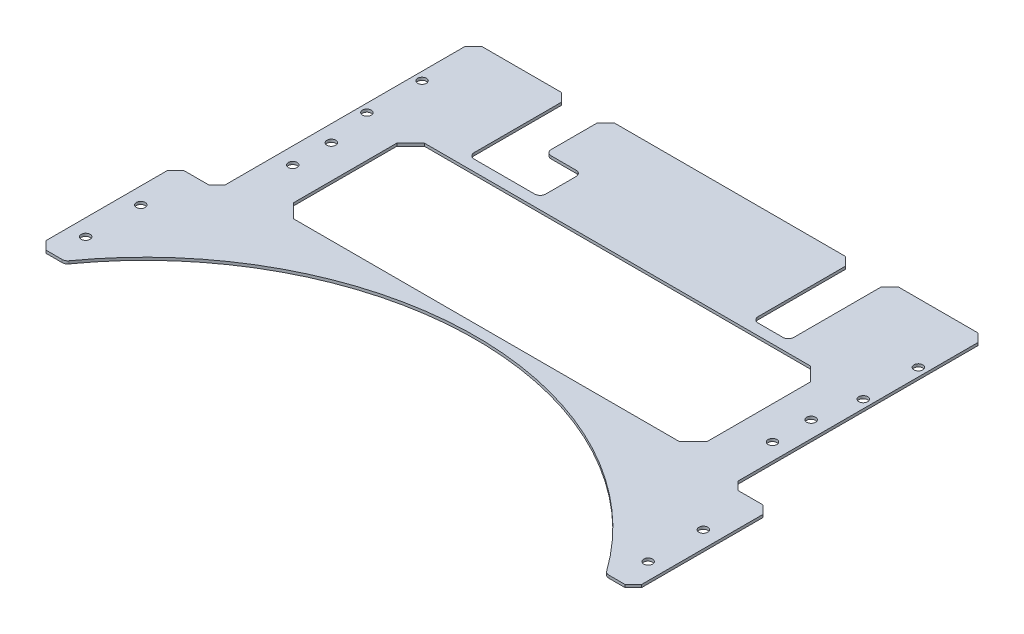
from build123d import *

# Parameters (mm, degrees)
SKETCH_1_W               = 186
SKETCH_1_H               = 110
EXTRUDE_1_DEPTH          = 1
SKETCH_2_R               = 1.6
CUT_EXTRUDE_1_DEPTH      = 2
EXTRUDE_2_DEPTH          = 1
SKETCH_6_R               = 120
CUT_EXTRUDE_2_DEPTH      = 2
SKETCH_8_W               = 186
SKETCH_8_H               = 2
EXTRUDE_3_DEPTH          = 1
SKETCH_7_R               = 1.25
SKETCH_7_R_2             = 1.6
CUT_EXTRUDE_3_DEPTH      = 2
CUT_EXTRUDE_4_DEPTH      = 2
SKETCH_10_W              = 8
SKETCH_10_H              = 15
CUT_EXTRUDE_5_DEPTH      = 2
SKETCH_11_W              = 150
SKETCH_11_H              = 47.5
CUT_EXTRUDE_6_DEPTH      = 2
CHAMFER_2_SIZE           = 5
SKETCH_12_R              = 1.6
CUT_EXTRUDE_7_DEPTH      = 2
SKETCH_14_W              = 3
SKETCH_14_H              = 36.77
CUT_EXTRUDE_8_DEPTH      = 1
CUT_EXTRUDE_8_DEPTH_BACK = 2
SKETCH_15_W              = 5
SKETCH_15_H              = 36.77
EXTRUDE_4_DEPTH          = 1
SKETCH_16_W              = 6
SKETCH_16_H              = 15
CUT_EXTRUDE_9_DEPTH      = 2
CHAMFER_1_SIZE           = 3
FILLET_1_R               = 2


with BuildPart() as part:
    # 草图1 → 凸台-拉伸1 (new body)
    with BuildSketch(Plane(origin=(0, 0, 0), x_dir=(1, 0, 0), z_dir=(0, 1, 0))):
        Rectangle(SKETCH_1_W, SKETCH_1_H)
    extrude(amount=EXTRUDE_1_DEPTH)

    # 草图2 → 切除-拉伸1 (cut, through all)
    with BuildSketch(Plane(origin=(0, 1, 0), x_dir=(1, 0, 0), z_dir=(0, 1, 0))):
        with Locations((90, 15.38)):
            Circle(SKETCH_2_R)
        with Locations((90, 35.38)):
            Circle(SKETCH_2_R)
        with Locations((-90, 35.38)):
            Circle(SKETCH_2_R)
        with Locations((-90, 15.38)):
            Circle(SKETCH_2_R)
    extrude(amount=-CUT_EXTRUDE_1_DEPTH, mode=Mode.SUBTRACT)

    # 草图5 → 凸台-拉伸2 (add)
    with BuildSketch(Plane(origin=(0, 1, 0), x_dir=(1, 0, 0), z_dir=(0, 1, 0))):
        Polygon((-108, -86), (108, -86), (108, -36), (93, -36), (93, -55), (-93, -55), (-93, -36), (-108, -36), align=None)
    extrude(amount=-EXTRUDE_2_DEPTH)

    # 草图6 → 切除-拉伸2 (cut, through all)
    with BuildSketch(Plane(origin=(0, 1, 0), x_dir=(1, 0, 0), z_dir=(0, 1, 0))):
        with Locations((0, -155.12)):
            Circle(SKETCH_6_R)
    extrude(amount=-CUT_EXTRUDE_2_DEPTH, mode=Mode.SUBTRACT)

    # 草图8 → 凸台-拉伸3 (add)
    with BuildSketch(Plane(origin=(0, 1, 0), x_dir=(1, 0, 0), z_dir=(0, 1, 0))):
        with Locations((0, 56)):
            Rectangle(SKETCH_8_W, SKETCH_8_H)
    extrude(amount=-EXTRUDE_3_DEPTH)

    # 草图7 → 切除-拉伸3 (cut, through all)
    with BuildSketch(Plane(origin=(0, 1, 0), x_dir=(1, 0, 0), z_dir=(0, 1, 0))):
        with Locations((47.5, 46.38)):
            Circle(SKETCH_7_R)
        with Locations((47.5, 53.88)):
            Circle(SKETCH_7_R)
        with Locations((102, -74.62)):
            Circle(SKETCH_7_R_2)
        with Locations((102, -54.62)):
            Circle(SKETCH_7_R_2)
        with Locations((-102, -54.62)):
            Circle(SKETCH_7_R_2)
        with Locations((-102, -74.62)):
            Circle(SKETCH_7_R_2)
        with Locations((-47.5, 53.88)):
            Circle(SKETCH_7_R)
        with Locations((-47.5, 46.38)):
            Circle(SKETCH_7_R)
    extrude(amount=-CUT_EXTRUDE_3_DEPTH, mode=Mode.SUBTRACT)

    # 草图9 → 切除-拉伸4 (cut, through all)
    with BuildSketch(Plane(origin=(0, 1, 0), x_dir=(1, 0, 0), z_dir=(0, 1, 0))):
        with BuildLine():
            Line((55, 52.23), (55, 20.23))
            Line((55, 20.23), (40, 20.23))
            Line((40, 20.23), (40, 52.23))
            Line((40, 52.23), (40, 66.764572681))
            ThreePointArc((40, 66.764572681), (40.878679656, 68.885893025), (43, 69.764572681))
            Line((43, 69.764572681), (52, 69.764572681))
            ThreePointArc((52, 69.764572681), (54.121320344, 68.885893025), (55, 66.764572681))
            Line((55, 66.764572681), (55, 52.23))
        make_face()
        with BuildLine():
            Line((-40, 66.764572681), (-40, 52.23))
            Line((-40, 52.23), (-40, 20.23))
            Line((-40, 20.23), (-55, 20.23))
            Line((-55, 20.23), (-55, 52.23))
            Line((-55, 52.23), (-55, 66.764572681))
            ThreePointArc((-55, 66.764572681), (-54.121320344, 68.885893025), (-52, 69.764572681))
            Line((-52, 69.764572681), (-43, 69.764572681))
            ThreePointArc((-43, 69.764572681), (-40.878679656, 68.885893025), (-40, 66.764572681))
        make_face()
    extrude(amount=-CUT_EXTRUDE_4_DEPTH, mode=Mode.SUBTRACT)

    # 草图10 → 切除-拉伸5 (cut, through all)
    with BuildSketch(Plane(origin=(0, 1, 0), x_dir=(1, 0, 0), z_dir=(0, 1, 0))):
        with Locations((-36, 27.73)):
            Rectangle(SKETCH_10_W, SKETCH_10_H)
    extrude(amount=-CUT_EXTRUDE_5_DEPTH, mode=Mode.SUBTRACT)

    # 草图11 → 切除-拉伸6 (cut, through all)
    with BuildSketch(Plane(origin=(0, 1, 0), x_dir=(1, 0, 0), z_dir=(0, 1, 0))):
        with Locations((0, -7.52)):
            Rectangle(SKETCH_11_W, SKETCH_11_H)
    extrude(amount=-CUT_EXTRUDE_6_DEPTH, mode=Mode.SUBTRACT)

    # 倒角2
    chamfer_2_edges = [part.edges().sort_by_distance(p)[0] for p in [
        (75, 0.5, -16.23),
        (75, 0.5, 31.27),
        (-75, 0.5, 31.27),
        (-75, 0.5, -16.23),
    ]]
    chamfer(chamfer_2_edges, length=CHAMFER_2_SIZE)

    # 草图12 → 切除-拉伸7 (cut, through all)
    with BuildSketch(Plane(origin=(0, 1, 0), x_dir=(1, 0, 0), z_dir=(0, 1, 0))):
        with Locations((-87, -0.52)):
            Circle(SKETCH_12_R)
        with Locations((-87, -14.52)):
            Circle(SKETCH_12_R)
        with Locations((87, -14.52)):
            Circle(SKETCH_12_R)
        with Locations((87, -0.52)):
            Circle(SKETCH_12_R)
    extrude(amount=-CUT_EXTRUDE_7_DEPTH, mode=Mode.SUBTRACT)

    # 草图14 → 切除-拉伸8 (cut, two sides)
    with BuildSketch(Plane(origin=(0, 1, 0), x_dir=(1, 0, 0), z_dir=(0, 1, 0))) as cut_extrude_8_sk:
        with Locations((-56.5, 38.615)):
            Rectangle(SKETCH_14_W, SKETCH_14_H)
        with Locations((56.5, 38.615)):
            Rectangle(SKETCH_14_W, SKETCH_14_H)
    extrude(amount=CUT_EXTRUDE_8_DEPTH, mode=Mode.SUBTRACT)
    extrude(cut_extrude_8_sk.sketch, amount=-CUT_EXTRUDE_8_DEPTH_BACK, mode=Mode.SUBTRACT)

    # 草图15 → 凸台-拉伸4 (add)
    with BuildSketch(Plane(origin=(0, 1, 0), x_dir=(1, 0, 0), z_dir=(0, 1, 0))):
        with Locations((42.5, 38.615)):
            Rectangle(SKETCH_15_W, SKETCH_15_H)
        with Locations((-42.5, 38.615)):
            Rectangle(SKETCH_15_W, SKETCH_15_H)
    extrude(amount=-EXTRUDE_4_DEPTH)

    # 草图16 → 切除-拉伸9 (cut, through all)
    with BuildSketch(Plane(origin=(0, 1, 0), x_dir=(1, 0, 0), z_dir=(0, 1, 0))):
        with Locations((-42, 27.73)):
            Rectangle(SKETCH_16_W, SKETCH_16_H)
    extrude(amount=-CUT_EXTRUDE_9_DEPTH, mode=Mode.SUBTRACT)

    # 倒角1
    chamfer_1_edges = [part.edges().sort_by_distance(p)[0] for p in [
        (-58, 0.5, -57),
        (58, 0.5, -57),
        (-45, 0.5, -57),
        (45, 0.5, -57),
        (-93, 0.5, 36),
        (93, 0.5, 36),
        (108, 0.5, 36),
        (108, 0.5, 86),
        (-108, 0.5, 86),
        (-108, 0.5, 36),
        (93, 0.5, -57),
        (-93, 0.5, -57),
    ]]
    chamfer(chamfer_1_edges, length=CHAMFER_1_SIZE)

    # 圆角1
    fillet_1_edges = [part.edges().sort_by_distance(p)[0] for p in [
        (-32, 0.5, -35.23),
        (-32, 0.5, -20.23),
        (-58, 0.5, -20.23),
        (58, 0.5, -20.23),
        (45, 0.5, -20.23),
        (-45, 0.5, -35.23),
        (-98.093963117, 0.5, 86),
        (98.093963117, 0.5, 86),
    ]]
    fillet(fillet_1_edges, radius=FILLET_1_R)


solid = part.part
